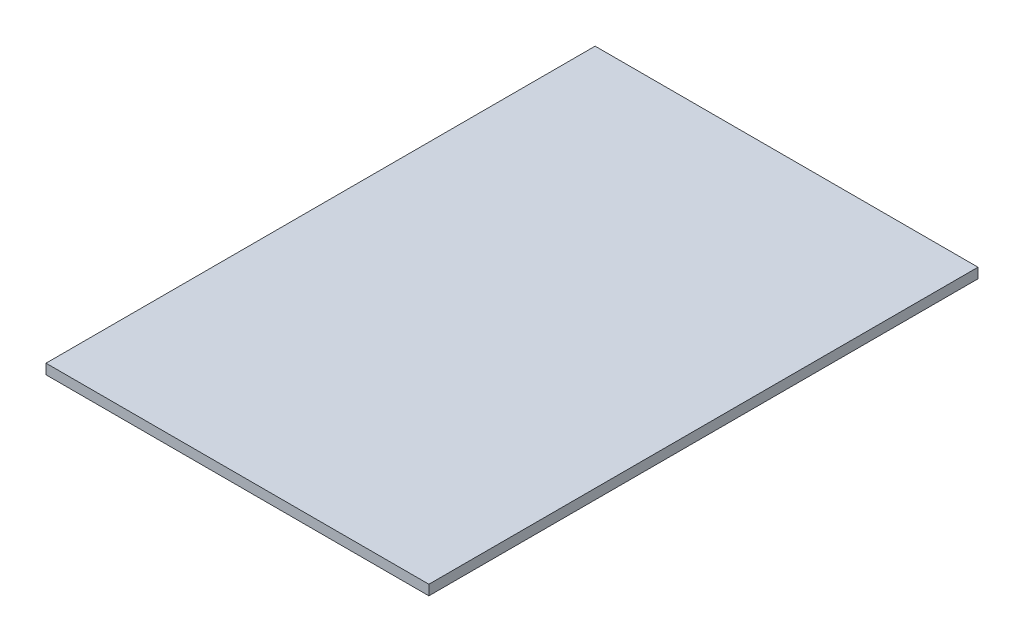
from build123d import *

# Parameters (mm, degrees)
BOSS_EXTRUDE1_DEPTH = 4


with BuildPart() as part:
    # Sketch1 → Boss-Extrude1 (new body)
    with BuildSketch(Plane(origin=(0, 0, 0), x_dir=(1, 0, 0), z_dir=(0, 1, 0))):
        Polygon((-74, 105), (-74, 109), (78, 109), (78, -109), (-74, -109), (-74, -105), align=None)
    extrude(amount=BOSS_EXTRUDE1_DEPTH)


solid = part.part
